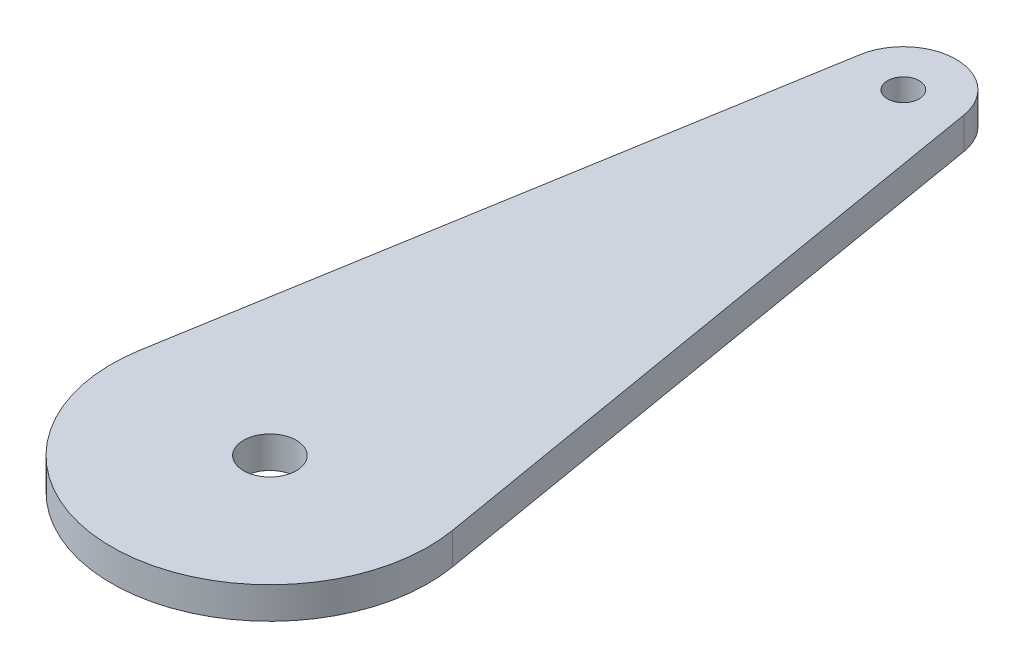
from build123d import *

# Parameters (mm, degrees)
SKETCH1_R           = 1.5
BOSS_EXTRUDE1_DEPTH = 3
SKETCH2_R           = 2.5
CUT_EXTRUDE1_DEPTH  = 3


with BuildPart() as part:
    # Sketch1 → Boss-Extrude1 (new body)
    with BuildSketch(Plane(origin=(0, 0, 0), x_dir=(1, 0, 0), z_dir=(0, 1, 0))):
        with BuildLine():
            Line((-4.930066486, 60.833333333), (-14.790199458, 2.5))
            ThreePointArc((-14.790199458, 2.5), (0, -15), (14.790199458, 2.5))
            Line((14.790199458, 2.5), (4.930066486, 60.833333333))
            ThreePointArc((4.930066486, 60.833333333), (0, 65), (-4.930066486, 60.833333333))
        make_face()
        with Locations((0, 60)):
            Circle(SKETCH1_R, mode=Mode.SUBTRACT)
    extrude(amount=BOSS_EXTRUDE1_DEPTH)

    # Sketch2 → Cut-Extrude1 (cut)
    with BuildSketch(Plane(origin=(0, 3, 0), x_dir=(1, 0, 0), z_dir=(0, 1, 0))):
        Circle(SKETCH2_R)
    extrude(amount=-CUT_EXTRUDE1_DEPTH, mode=Mode.SUBTRACT)


solid = part.part
